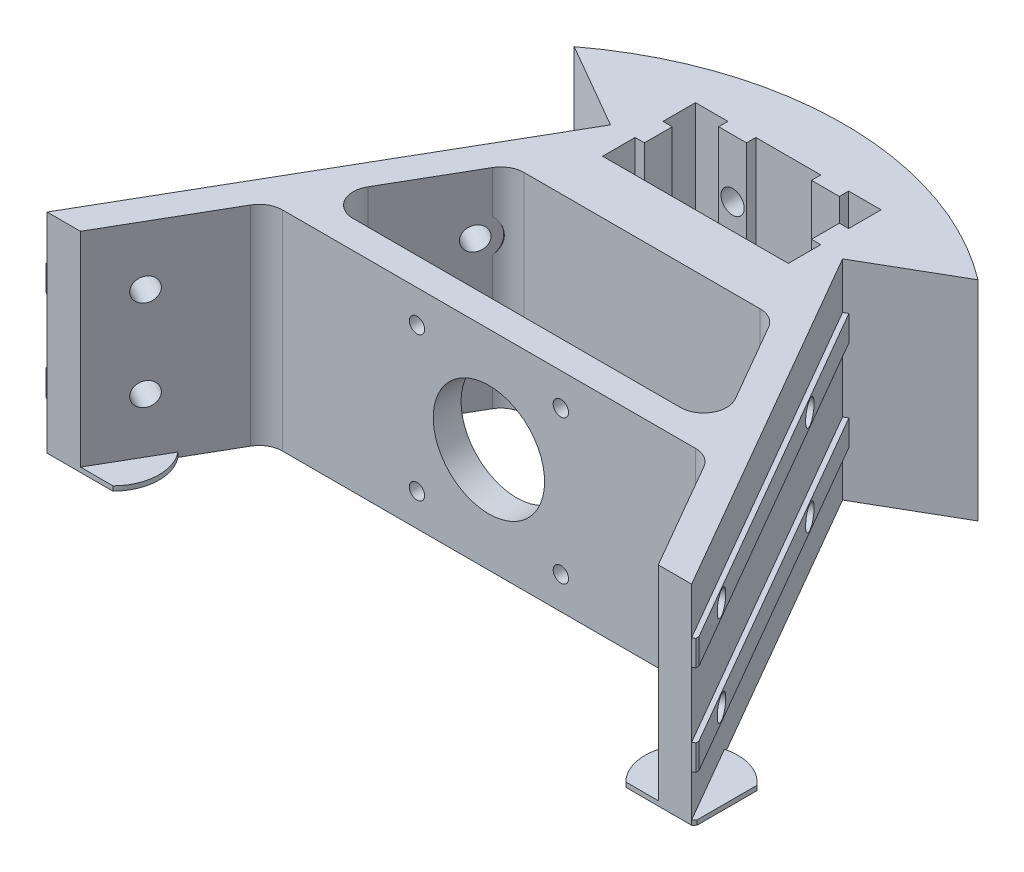
from build123d import *

# Parameters (mm, degrees)
BOSS_EXTRUDE1_DEPTH     = 45
CUT_EXTRUDE1_REACH      = 115.721
SKETCH2_R               = 12
SKETCH2_R_2             = 1.65
SKETCH3_W               = 92.200496998
SKETCH3_H               = 5.5
BOSS_EXTRUDE2_DEPTH     = 1
CUT_EXTRUDE2_REACH      = 136.947
SKETCH4_R               = 2.5
CUT_EXTRUDE6_REACH      = 130.334
SKETCH7_R               = 4.5
CUT_EXTRUDE3_REACH      = 126.549
CUT_EXTRUDE3_END_RADIUS = 72
SKETCH5_R               = 2.5
CUT_EXTRUDE5_START      = -14
SKETCH6_R               = 4.25
CUT_EXTRUDE5_DEPTH      = 1.7
SKETCH8_R               = 10
BOSS_EXTRUDE3_DEPTH     = 1
CUT_EXTRUDE7_DEPTH      = 113.319357745


with BuildPart() as part:
    # Sketch1 → Boss-Extrude1 (new body)
    with BuildSketch(Plane(origin=(0, 0, 0), x_dir=(1, 0, 0), z_dir=(0, 1, 0))):
        with BuildLine():
            Line((67.073634163, -66.174942219), (25, 6.698729811))
            Line((25, 6.698729811), (43.49555567, 17.377143855))
            ThreePointArc((43.49555567, 17.377143855), (0, 32), (-43.49555567, 17.377143855))
            Line((-43.49555567, 17.377143855), (-25, 6.698729811))
            Line((-25, 6.698729811), (-67.073634163, -66.174942219))
            Line((-67.073634163, -66.174942219), (-71.100248499, -73.149242831))
            Line((-71.100248499, -73.149242831), (-63.915003714, -73.149242831))
            Line((-63.915003714, -73.149242831), (-48.817731326, -47))
            ThreePointArc((-48.817731326, -47), (-46.987604307, -45.169872981), (-44.487604307, -44.5))
            Line((-44.487604307, -44.5), (44.487604307, -44.5))
            ThreePointArc((44.487604307, -44.5), (46.987604307, -45.169872981), (48.817731326, -47))
            Line((48.817731326, -47), (63.915003714, -73.149242831))
            Line((63.915003714, -73.149242831), (71.100248499, -73.149242831))
            Line((71.100248499, -73.149242831), (67.073634163, -66.174942219))
        make_face()
        Polygon((-20, 20), (-13, 20), (-13, 18), (-7, 18), (-7, 20), (7, 20), (7, 18), (13, 18), (13, 20), (20, 20), (20, 13), (18, 13), (18, 7), (20, 7), (20, 0), (-20, 0), (-20, 7), (-18, 7), (-18, 13), (-20, 13), align=None, mode=Mode.SUBTRACT)
        with BuildLine():
            Line((-25.435045424, -11.5), (25.435045424, -11.5))
            ThreePointArc((25.435045424, -11.5), (27.935045424, -12.169872981), (29.765172443, -14))
            Line((29.765172443, -14), (39.580127019, -31))
            ThreePointArc((39.580127019, -31), (39.580127019, -36), (35.25, -38.5))
            Line((35.25, -38.5), (-35.25, -38.5))
            ThreePointArc((-35.25, -38.5), (-39.580127019, -36), (-39.580127019, -31))
            Line((-39.580127019, -31), (-29.765172443, -14))
            ThreePointArc((-29.765172443, -14), (-27.935045424, -12.169872981), (-25.435045424, -11.5))
        make_face(mode=Mode.SUBTRACT)
    extrude(amount=BOSS_EXTRUDE1_DEPTH)

    # Sketch2 → Cut-Extrude1 (cut, up to next)
    with BuildSketch(Plane.XY.offset(44.5), mode=Mode.PRIVATE) as cut_extrude1_sk1:
        with Locations((0, 22.5)):
            Circle(SKETCH2_R)
    cut_extrude1_tool1 = extrude(cut_extrude1_sk1.sketch, amount=-CUT_EXTRUDE1_REACH, mode=Mode.PRIVATE) & part.part
    # Sketch2 → Cut-Extrude1 (cut, up to next)
    with BuildSketch(Plane.XY.offset(44.5), mode=Mode.PRIVATE) as cut_extrude1_sk2:
        with Locations((-15.5, 38)):
            Circle(SKETCH2_R_2)
    cut_extrude1_tool2 = extrude(cut_extrude1_sk2.sketch, amount=-CUT_EXTRUDE1_REACH, mode=Mode.PRIVATE) & part.part
    # Sketch2 → Cut-Extrude1 (cut, up to next)
    with BuildSketch(Plane.XY.offset(44.5), mode=Mode.PRIVATE) as cut_extrude1_sk3:
        with Locations((15.5, 38)):
            Circle(SKETCH2_R_2)
    cut_extrude1_tool3 = extrude(cut_extrude1_sk3.sketch, amount=-CUT_EXTRUDE1_REACH, mode=Mode.PRIVATE) & part.part
    # Sketch2 → Cut-Extrude1 (cut, up to next)
    with BuildSketch(Plane.XY.offset(44.5), mode=Mode.PRIVATE) as cut_extrude1_sk4:
        with Locations((15.5, 7)):
            Circle(SKETCH2_R_2)
    cut_extrude1_tool4 = extrude(cut_extrude1_sk4.sketch, amount=-CUT_EXTRUDE1_REACH, mode=Mode.PRIVATE) & part.part
    # Sketch2 → Cut-Extrude1 (cut, up to next)
    with BuildSketch(Plane.XY.offset(44.5), mode=Mode.PRIVATE) as cut_extrude1_sk5:
        with Locations((-15.5, 7)):
            Circle(SKETCH2_R_2)
    cut_extrude1_tool5 = extrude(cut_extrude1_sk5.sketch, amount=-CUT_EXTRUDE1_REACH, mode=Mode.PRIVATE) & part.part
    add(cut_extrude1_tool1.solids().sort_by_distance((0, 22.5, 44.5))[0], mode=Mode.SUBTRACT)
    add(cut_extrude1_tool2.solids().sort_by_distance((-15.5, 38, 44.5))[0], mode=Mode.SUBTRACT)
    add(cut_extrude1_tool3.solids().sort_by_distance((15.5, 38, 44.5))[0], mode=Mode.SUBTRACT)
    add(cut_extrude1_tool4.solids().sort_by_distance((15.5, 7, 44.5))[0], mode=Mode.SUBTRACT)
    add(cut_extrude1_tool5.solids().sort_by_distance((-15.5, 7, 44.5))[0], mode=Mode.SUBTRACT)

    # Sketch3 → Boss-Extrude2 (add)
    with BuildSketch(Plane(origin=(21.650635095, 0, -12.5), x_dir=(-0.49999999999999517, 0, -0.8660254037844414), z_dir=(0.8660254037844414, 0, -0.49999999999999517))):
        with Locations((-52.79897831, 32.25)):
            Rectangle(SKETCH3_W, SKETCH3_H)
        with Locations((-52.79897831, 12.75)):
            Rectangle(SKETCH3_W, SKETCH3_H)
    boss_extrude2 = extrude(amount=BOSS_EXTRUDE2_DEPTH)

    # Sketch4 → Cut-Extrude2 (cut, up to next)
    with BuildSketch(Plane(origin=(22.516660498, 0, -13), x_dir=(-0.4999999999999952, 0, -0.8660254037844415), z_dir=(0.8660254037844415, 0, -0.4999999999999953)), mode=Mode.PRIVATE) as cut_extrude2_sk1:
        with Locations((-29.698729811, 32.25)):
            Circle(SKETCH4_R)
    cut_extrude2_tool1 = extrude(cut_extrude2_sk1.sketch, amount=-CUT_EXTRUDE2_REACH, mode=Mode.PRIVATE) & part.part
    # Sketch4 → Cut-Extrude2 (cut, up to next)
    with BuildSketch(Plane(origin=(22.516660498, 0, -13), x_dir=(-0.4999999999999952, 0, -0.8660254037844415), z_dir=(0.8660254037844415, 0, -0.4999999999999953)), mode=Mode.PRIVATE) as cut_extrude2_sk2:
        with Locations((-29.698729811, 12.75)):
            Circle(SKETCH4_R)
    cut_extrude2_tool2 = extrude(cut_extrude2_sk2.sketch, amount=-CUT_EXTRUDE2_REACH, mode=Mode.PRIVATE) & part.part
    # Sketch4 → Cut-Extrude2 (cut, up to next)
    with BuildSketch(Plane(origin=(22.516660498, 0, -13), x_dir=(-0.4999999999999952, 0, -0.8660254037844415), z_dir=(0.8660254037844415, 0, -0.4999999999999953)), mode=Mode.PRIVATE) as cut_extrude2_sk3:
        with Locations((-81.698729811, 12.75)):
            Circle(SKETCH4_R)
    cut_extrude2_tool3 = extrude(cut_extrude2_sk3.sketch, amount=-CUT_EXTRUDE2_REACH, mode=Mode.PRIVATE) & part.part
    # Sketch4 → Cut-Extrude2 (cut, up to next)
    with BuildSketch(Plane(origin=(22.516660498, 0, -13), x_dir=(-0.4999999999999952, 0, -0.8660254037844415), z_dir=(0.8660254037844415, 0, -0.4999999999999953)), mode=Mode.PRIVATE) as cut_extrude2_sk4:
        with Locations((-81.698729811, 32.25)):
            Circle(SKETCH4_R)
    cut_extrude2_tool4 = extrude(cut_extrude2_sk4.sketch, amount=-CUT_EXTRUDE2_REACH, mode=Mode.PRIVATE) & part.part
    cut_extrude2_1 = cut_extrude2_tool1.solids().sort_by_distance((37.366025, 32.25, 12.719854))[0]
    add(cut_extrude2_1, mode=Mode.SUBTRACT)
    cut_extrude2_2 = cut_extrude2_tool2.solids().sort_by_distance((37.366025, 12.75, 12.719854))[0]
    add(cut_extrude2_2, mode=Mode.SUBTRACT)
    cut_extrude2_3 = cut_extrude2_tool3.solids().sort_by_distance((63.366025, 12.75, 57.753175))[0]
    add(cut_extrude2_3, mode=Mode.SUBTRACT)
    cut_extrude2_4 = cut_extrude2_tool4.solids().sort_by_distance((63.366025, 32.25, 57.753175))[0]
    add(cut_extrude2_4, mode=Mode.SUBTRACT)
    cut_extrude2 = cut_extrude2_1 + cut_extrude2_2 + cut_extrude2_3 + cut_extrude2_4  # Cut-Extrude2 as one shape, for the pattern or mirror that repeats it

    # Sketch7 → Cut-Extrude6 (cut, up to next)
    with BuildSketch(Plane(origin=(16.261701506, 0, -9.388697742), x_dir=(0.49999999999999534, 0, 0.8660254037844414), z_dir=(-0.8660254037844415, 0, 0.4999999999999954)), mode=Mode.PRIVATE) as cut_extrude6_sk1:
        with Locations((29.698729811, 32.25)):
            Circle(SKETCH7_R)
    cut_extrude6_tool1 = extrude(cut_extrude6_sk1.sketch, amount=CUT_EXTRUDE6_REACH, mode=Mode.PRIVATE) & part.part
    # Sketch7 → Cut-Extrude6 (cut, up to next)
    with BuildSketch(Plane(origin=(16.261701506, 0, -9.388697742), x_dir=(0.49999999999999534, 0, 0.8660254037844414), z_dir=(-0.8660254037844415, 0, 0.4999999999999954)), mode=Mode.PRIVATE) as cut_extrude6_sk2:
        with Locations((29.698729811, 12.75)):
            Circle(SKETCH7_R)
    cut_extrude6_tool2 = extrude(cut_extrude6_sk2.sketch, amount=CUT_EXTRUDE6_REACH, mode=Mode.PRIVATE) & part.part
    cut_extrude6_1 = cut_extrude6_tool1.solids().sort_by_distance((31.111066, 32.25, 16.331157))[0]
    add(cut_extrude6_1, mode=Mode.SUBTRACT)
    cut_extrude6_2 = cut_extrude6_tool2.solids().sort_by_distance((31.111066, 12.75, 16.331157))[0]
    add(cut_extrude6_2, mode=Mode.SUBTRACT)
    cut_extrude6 = cut_extrude6_1 + cut_extrude6_2  # Cut-Extrude6 as one shape, for the pattern or mirror that repeats it

    # Cut-Extrude3: up to this cylinder (the profile starts inside it)
    cut_extrude3_end = Plane(origin=(0, 22.5, 40), z_dir=(0, -1, 0)) * Cylinder(CUT_EXTRUDE3_END_RADIUS, 418.098, mode=Mode.PRIVATE)
    # Sketch5 → Cut-Extrude3 (cut, up to the surface)
    with BuildSketch(Plane.XY.offset(-18), mode=Mode.PRIVATE) as cut_extrude3_sk1:
        with Locations((10, 32.5)):
            Circle(SKETCH5_R)
    cut_extrude3_tool1 = extrude(cut_extrude3_sk1.sketch, amount=-CUT_EXTRUDE3_REACH, mode=Mode.PRIVATE) & cut_extrude3_end
    # Sketch5 → Cut-Extrude3 (cut, up to the surface)
    with BuildSketch(Plane.XY.offset(-18), mode=Mode.PRIVATE) as cut_extrude3_sk2:
        with Locations((10, 12.5)):
            Circle(SKETCH5_R)
    cut_extrude3_tool2 = extrude(cut_extrude3_sk2.sketch, amount=-CUT_EXTRUDE3_REACH, mode=Mode.PRIVATE) & cut_extrude3_end
    cut_extrude3 = cut_extrude3_tool1.solids().sort_by_distance((10, 32.5, -18))[0] + cut_extrude3_tool2.solids().sort_by_distance((10, 12.5, -18))[0]
    add(cut_extrude3, mode=Mode.SUBTRACT)

    # Sketch6 → Cut-Extrude5 (cut)
    with BuildSketch(Plane.XY.offset(-18).offset(CUT_EXTRUDE5_START)):
        with Locations(Location((10, 32.5, 0), (0, 0, 180))):
            Circle(SKETCH6_R)
        with Locations(Location((10, 12.5, 0), (0, 0, 180))):
            Circle(SKETCH6_R)
    cut_extrude5 = extrude(amount=CUT_EXTRUDE5_DEPTH, mode=Mode.SUBTRACT)

    # Mirror1: Boss-Extrude2, Cut-Extrude2, Cut-Extrude6, Cut-Extrude3, Cut-Extrude5 across plane
    add(boss_extrude2.mirror(Plane(origin=(0, 0, 0), x_dir=(0, 0, 1), z_dir=(1, 0, 0))))
    add(cut_extrude2.mirror(Plane(origin=(0, 0, 0), x_dir=(0, 0, 1), z_dir=(1, 0, 0))), mode=Mode.SUBTRACT)
    add(cut_extrude6.mirror(Plane(origin=(0, 0, 0), x_dir=(0, 0, 1), z_dir=(1, 0, 0))), mode=Mode.SUBTRACT)
    add(cut_extrude3.mirror(Plane(origin=(0, 0, 0), x_dir=(0, 0, 1), z_dir=(1, 0, 0))), mode=Mode.SUBTRACT)
    add(cut_extrude5.mirror(Plane(origin=(0, 0, 0), x_dir=(0, 0, 1), z_dir=(1, 0, 0))), mode=Mode.SUBTRACT)

    # Sketch8 → Boss-Extrude3 (add)
    with BuildSketch(Plane(origin=(0, 0, 0), x_dir=(1, 0, 0), z_dir=(0, 1, 0))):
        with Locations((62.338794406, -63.196563711)):
            Circle(SKETCH8_R)
        with Locations((-62.338794406, -63.196563711)):
            Circle(SKETCH8_R)
    extrude(amount=BOSS_EXTRUDE3_DEPTH)

    # Sketch12 → Cut-Extrude7 (cut, through all)
    with BuildSketch(Plane(origin=(0, 0, 0), x_dir=(1, 0, 0), z_dir=(0, 1, 0))):
        Polygon((80, -70.249242831), (80, -53.149242831), (70, -53.149242831), (70, -69.917804932), (69.425932718, -70.249242831), (-69.425932718, -70.249242831), (-70, -69.917804932), (-70, -53.149242831), (-80, -53.149242831), (-80, -70.249242831), (-80, -75.149242831), (80, -75.149242831), align=None)
    extrude(amount=CUT_EXTRUDE7_DEPTH, mode=Mode.SUBTRACT)


solid = part.part
